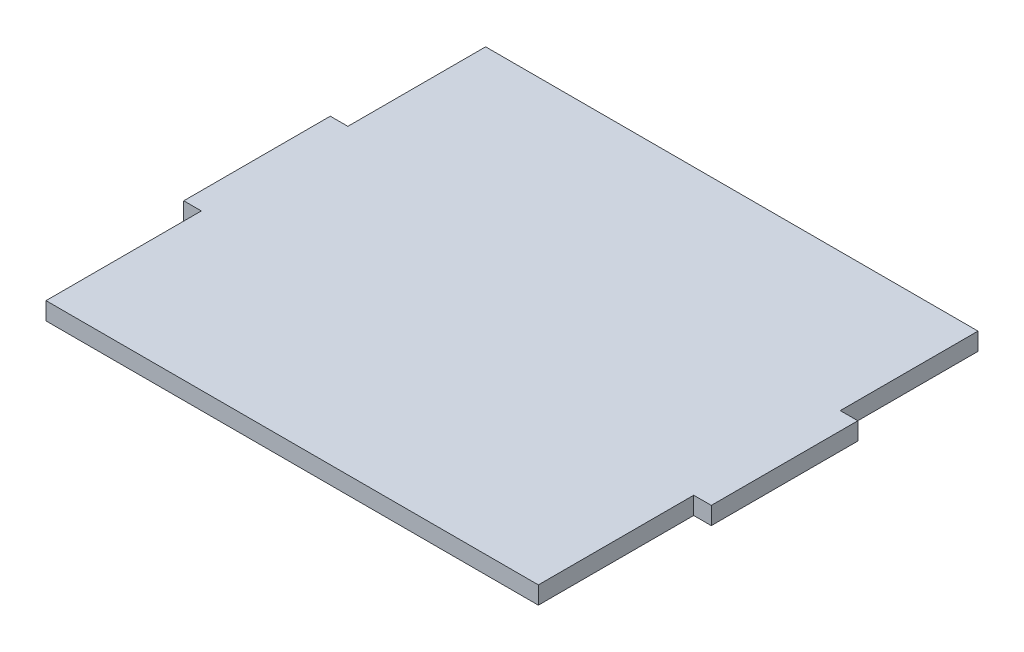
from build123d import *

# Parameters (mm, degrees)
SKETCH1_W           = 76.2
SKETCH1_H           = 63.5
BOSS_EXTRUDE1_DEPTH = 2.54
SKETCH2_W           = 2.54
SKETCH2_H           = 19.8966582
CUT_EXTRUDE1_DEPTH  = 3.54
SKETCH3_W           = 2.54
SKETCH3_H           = 22.4366582
SKETCH3_H_2         = 19.8966582
CUT_EXTRUDE2_DEPTH  = 3.54


with BuildPart() as part:
    # Sketch1 → Boss-Extrude1 (new body)
    with BuildSketch(Plane(origin=(0, 0, 0), x_dir=(1, 0, 0), z_dir=(0, 1, 0))):
        with Locations((38.1, 31.75)):
            Rectangle(SKETCH1_W, SKETCH1_H)
    extrude(amount=BOSS_EXTRUDE1_DEPTH)

    # Sketch2 → Cut-Extrude1 (cut, through all)
    with BuildSketch(Plane(origin=(0, 2.54, 0), x_dir=(1, 0, 0), z_dir=(0, 1, 0))):
        with Locations((1.27, 53.5516709)):
            Rectangle(SKETCH2_W, SKETCH2_H)
    extrude(amount=-CUT_EXTRUDE1_DEPTH, mode=Mode.SUBTRACT)

    # Sketch3 → Cut-Extrude2 (cut, through all)
    with BuildSketch(Plane(origin=(0, 2.54, 0), x_dir=(1, 0, 0), z_dir=(0, 1, 0))):
        with Locations((1.27, 11.2183291)):
            Rectangle(SKETCH3_W, SKETCH3_H)
        with Locations((74.93, 53.5516709)):
            Rectangle(SKETCH3_W, SKETCH3_H_2)
        with Locations((74.93, 11.2183291)):
            Rectangle(SKETCH3_W, SKETCH3_H)
    extrude(amount=-CUT_EXTRUDE2_DEPTH, mode=Mode.SUBTRACT)


solid = part.part
